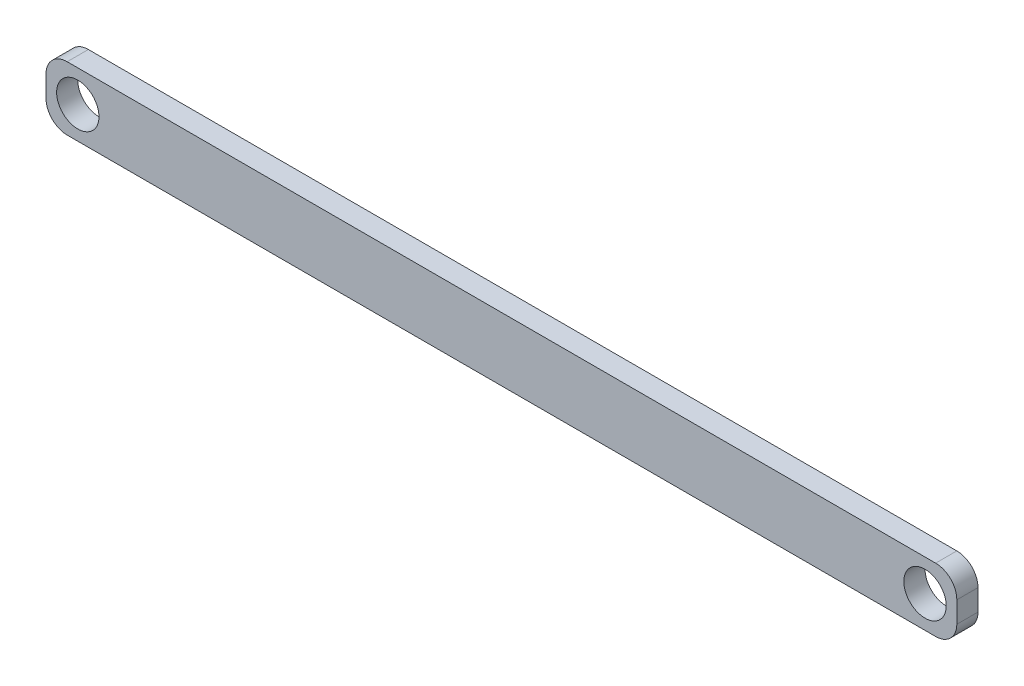
from build123d import *

# Parameters (mm, degrees)
CROQUIS1_R              = 10
SALIENTE_EXTRUIR2_DEPTH = 5


with BuildPart() as part:
    # Croquis1 → Saliente-Extruir2 (new body, symmetric)
    with BuildSketch(Plane.XY):
        with BuildLine():
            Line((-205, 15), (205, 15))
            ThreePointArc((205, 15), (212.071067812, 12.071067812), (215, 5))
            Line((215, 5), (215, -5))
            ThreePointArc((215, -5), (212.071067812, -12.071067812), (205, -15))
            Line((205, -15), (-205, -15))
            ThreePointArc((-205, -15), (-212.071067812, -12.071067812), (-215, -5))
            Line((-215, -5), (-215, 5))
            ThreePointArc((-215, 5), (-212.071067812, 12.071067812), (-205, 15))
        make_face()
        with Locations((-200, 0)):
            Circle(CROQUIS1_R, mode=Mode.SUBTRACT)
        with Locations((200, 0)):
            Circle(CROQUIS1_R, mode=Mode.SUBTRACT)
    extrude(amount=SALIENTE_EXTRUIR2_DEPTH, both=True)


solid = part.part
